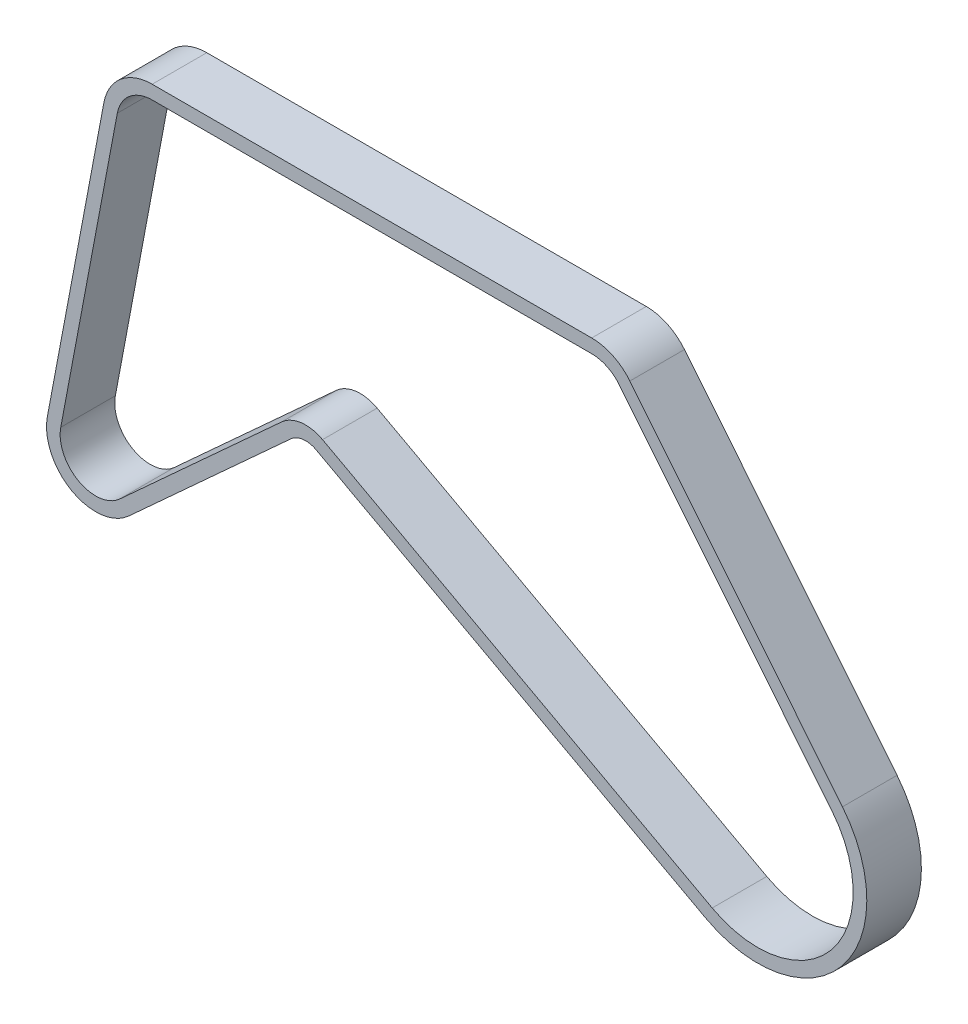
from build123d import *

# Parameters (mm, degrees)
EXTRUDE_THIN1_DEPTH = 10


with BuildPart() as part:
    # Sketch2 → Extrude-Thin1 (new, symmetric)
    with BuildSketch(Plane.XY):
        with BuildLine():
            Line((-161.781383655, 42.036480739), (-19.031512561, -35.182403693))
            ThreePointArc((-19.031512561, -35.182403693), (30.775705763, -25.551045669), (31.081700633, 25.177924573))
            Line((31.081700633, 25.177924573), (-46.806938551, 121.330066058))
            ThreePointArc((-46.806938551, 121.330066058), (-53.045839261, 126.247171893), (-60.793703836, 128))
            Line((-60.793703836, 128), (-221.819075448, 128))
            ThreePointArc((-221.819075448, 128), (-233.30903916, 123.855711237), (-239.508144262, 113.331192655))
            Line((-239.508144262, 113.331192655), (-260.223264765, 3.331192655))
            ThreePointArc((-260.223264765, 3.331192655), (-251.300991125, -15.720792041), (-230.403245845, -13.29812203))
            Line((-230.403245845, -13.29812203), (-170.979219548, 40.910276458))
            ThreePointArc((-170.979219548, 40.910276458), (-166.559963518, 42.940697498), (-161.781383655, 42.036480739))
        make_face()
        with BuildLine():
            Line((-159.402444585, 46.4342812), (-16.652573491, -30.784603232))
            ThreePointArc((-16.652573491, -30.784603232), (26.928742543, -22.35716496), (27.196488054, 22.030684001))
            Line((27.196488054, 22.030684001), (-50.69215113, 118.182825486))
            ThreePointArc((-50.69215113, 118.182825486), (-55.198023865, 121.734068589), (-60.793703836, 123))
            Line((-60.793703836, 123), (-221.819075448, 123))
            ThreePointArc((-221.819075448, 123), (-230.117382574, 120.00690256), (-234.594514036, 112.405861362))
            Line((-234.594514036, 112.405861362), (-255.309634539, 2.405861362))
            ThreePointArc((-255.309634539, 2.405861362), (-248.865770243, -11.353905363), (-233.772954208, -9.604199244))
            Line((-233.772954208, -9.604199244), (-174.348927911, 44.604199244))
            ThreePointArc((-174.348927911, 44.604199244), (-167.167636862, 47.903633434), (-159.402444585, 46.4342812))
        make_face(mode=Mode.SUBTRACT)
    extrude(amount=EXTRUDE_THIN1_DEPTH, both=True)


solid = part.part
